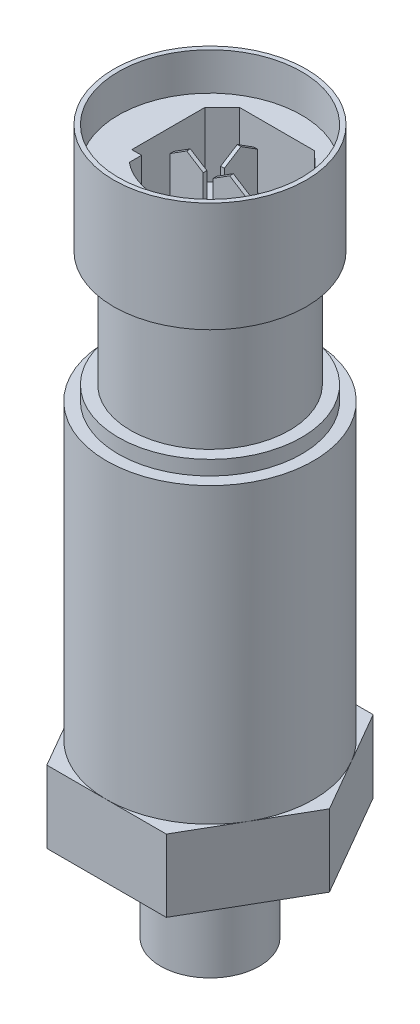
from build123d import *

# Parameters (mm, degrees)
SKETCH1_R           = 5.1435
BOSS_EXTRUDE1_DEPTH = 10.3
BOSS_EXTRUDE2_DEPTH = 7.5
SKETCH3_R           = 10.75
BOSS_EXTRUDE3_DEPTH = 30.48
SKETCH4_R           = 9.525
BOSS_EXTRUDE4_DEPTH = 1.5
SKETCH5_R           = 8.255
BOSS_EXTRUDE5_DEPTH = 12
SKETCH6_R           = 10
BOSS_EXTRUDE6_DEPTH = 11.4
SKETCH7_R           = 4.3053
CUT_EXTRUDE1_DEPTH  = 11.4
SKETCH28_R          = 4.3053
BOSS_EXTRUDE7_DEPTH = 11.4
SKETCH29_R          = 1.5
CUT_EXTRUDE2_DEPTH  = 11.4
SKETCH30_R          = 9.525
CUT_EXTRUDE6_DEPTH  = 10.638
SKETCH31_W          = 0.381
SKETCH31_H          = 3.44369911
SKETCH31_W_2        = 3.44369911
SKETCH31_H_2        = 0.381
BOSS_EXTRUDE8_DEPTH = 7.239
CUT_EXTRUDE7_DEPTH  = 6.731
CUT_EXTRUDE8_DEPTH  = 1.651
CUT_EXTRUDE9_DEPTH  = 1.651
SKETCH35_R          = 9.525
BOSS_EXTRUDE9_DEPTH = 6.731


with BuildPart() as part:
    # Sketch1 → Boss-Extrude1 (new body)
    with BuildSketch(Plane(origin=(0, 0, 0), x_dir=(1, 0, 0), z_dir=(0, 1, 0))):
        Circle(SKETCH1_R)
    extrude(amount=BOSS_EXTRUDE1_DEPTH)

    # Sketch2 → Boss-Extrude2 (add)
    with BuildSketch(Plane(origin=(0, 10.3, 0), x_dir=(1, 0, 0), z_dir=(0, 1, 0))):
        Polygon((6.206515394, 10.75), (-6.206515394, 10.75), (-12.413030788, 0), (-6.206515394, -10.75), (6.206515394, -10.75), (12.413030788, 0), align=None)
    extrude(amount=BOSS_EXTRUDE2_DEPTH)

    # Sketch3 → Boss-Extrude3 (add)
    with BuildSketch(Plane(origin=(0, 17.8, 0), x_dir=(1, 0, 0), z_dir=(0, 1, 0))):
        Circle(SKETCH3_R)
    extrude(amount=BOSS_EXTRUDE3_DEPTH)

    # Sketch4 → Boss-Extrude4 (add)
    with BuildSketch(Plane(origin=(0, 48.28, 0), x_dir=(1, 0, 0), z_dir=(0, 1, 0))):
        Circle(SKETCH4_R)
    extrude(amount=BOSS_EXTRUDE4_DEPTH)

    # Sketch5 → Boss-Extrude5 (add)
    with BuildSketch(Plane(origin=(0, 49.78, 0), x_dir=(1, 0, 0), z_dir=(0, 1, 0))):
        Circle(SKETCH5_R)
    extrude(amount=BOSS_EXTRUDE5_DEPTH)

    # Sketch6 → Boss-Extrude6 (add)
    with BuildSketch(Plane(origin=(0, 61.78, 0), x_dir=(1, 0, 0), z_dir=(0, 1, 0))):
        Circle(SKETCH6_R)
    extrude(amount=BOSS_EXTRUDE6_DEPTH)

    # Sketch7 → Cut-Extrude1 (cut)
    with BuildSketch(Plane.XZ):
        Circle(SKETCH7_R)
    extrude(amount=-CUT_EXTRUDE1_DEPTH, mode=Mode.SUBTRACT)

    # Sketch28 → Boss-Extrude7 (add)
    with BuildSketch(Plane(origin=(0, 0, 0), x_dir=(-1, 0, 0), z_dir=(0, -1, 0))):
        Circle(SKETCH28_R)
    extrude(amount=-BOSS_EXTRUDE7_DEPTH)

    # Sketch29 → Cut-Extrude2 (cut)
    with BuildSketch(Plane.XZ):
        Circle(SKETCH29_R)
    extrude(amount=-CUT_EXTRUDE2_DEPTH, mode=Mode.SUBTRACT)

    # Sketch30 → Cut-Extrude6 (cut)
    with BuildSketch(Plane(origin=(0, 73.18, 0), x_dir=(1, 0, 0), z_dir=(0, 1, 0))):
        Circle(SKETCH30_R)
    extrude(amount=-CUT_EXTRUDE6_DEPTH, mode=Mode.SUBTRACT)

    # Sketch31 → Boss-Extrude8 (add)
    with BuildSketch(Plane(origin=(0, 62.542, 0), x_dir=(1, 0, 0), z_dir=(0, 1, 0))):
        with Locations((0, 3.0226)):
            Rectangle(SKETCH31_W, SKETCH31_H)
        with Locations((-2.2352, 0)):
            Rectangle(SKETCH31_W_2, SKETCH31_H_2)
        with Locations((2.2352, 0)):
            Rectangle(SKETCH31_W_2, SKETCH31_H_2)
    extrude(amount=BOSS_EXTRUDE8_DEPTH)

    # Sketch32 → Cut-Extrude7 (cut)
    with BuildSketch(Plane.XY.offset(0.1905)):
        Polygon((-3.957049555, 68.6888), (-2.2352, 69.781), (-3.957049555, 69.781), align=None)
        Polygon((-0.513350445, 69.781), (-2.2352, 69.781), (-0.513350445, 68.6888), align=None)
    extrude(amount=-CUT_EXTRUDE7_DEPTH, mode=Mode.SUBTRACT)

    # Sketch33 → Cut-Extrude8 (cut)
    with BuildSketch(Plane.XY.offset(0.1905)):
        Polygon((0.513350445, 68.6888), (2.2352, 69.781), (0.513350445, 69.781), align=None)
        Polygon((3.957049555, 69.781), (2.2352, 69.781), (3.957049555, 68.6888), align=None)
    extrude(amount=-CUT_EXTRUDE8_DEPTH, mode=Mode.SUBTRACT)

    # Sketch34 → Cut-Extrude9 (cut)
    with BuildSketch(Plane(origin=(0.1905, 0, 0), x_dir=(0, 0, -1), z_dir=(1, 0, 0))):
        Polygon((1.300750445, 68.6888), (3.0226, 69.781), (1.300750445, 69.781), align=None)
        Polygon((4.744449555, 69.781), (3.0226, 69.781), (4.744449555, 68.6888), align=None)
    extrude(amount=-CUT_EXTRUDE9_DEPTH, mode=Mode.SUBTRACT)

    # Sketch35 → Boss-Extrude9 (add)
    with BuildSketch(Plane(origin=(0, 62.542, 0), x_dir=(1, 0, 0), z_dir=(0, 1, 0))):
        Circle(SKETCH35_R)
        with BuildLine():
            ThreePointArc((-4.699, -3.683), (-0.167968835, -5.324730553), (4.363062329, -3.683))
            Line((4.363062329, -3.683), (4.363062329, -2.413))
            Line((4.363062329, -2.413), (5.715, -2.413))
            Line((5.715, -2.413), (5.715, 5.24229274))
            Line((5.715, 5.24229274), (3.860385896, 6.985))
            Line((3.860385896, 6.985), (-3.918948776, 6.985))
            Line((-3.918948776, 6.985), (-5.715, 5.188948776))
            Line((-5.715, 5.188948776), (-5.715, -2.413))
            Line((-5.715, -2.413), (-4.699, -2.413))
            Line((-4.699, -2.413), (-4.699, -3.683))
        make_face(mode=Mode.SUBTRACT)
    extrude(amount=BOSS_EXTRUDE9_DEPTH)


solid = part.part
